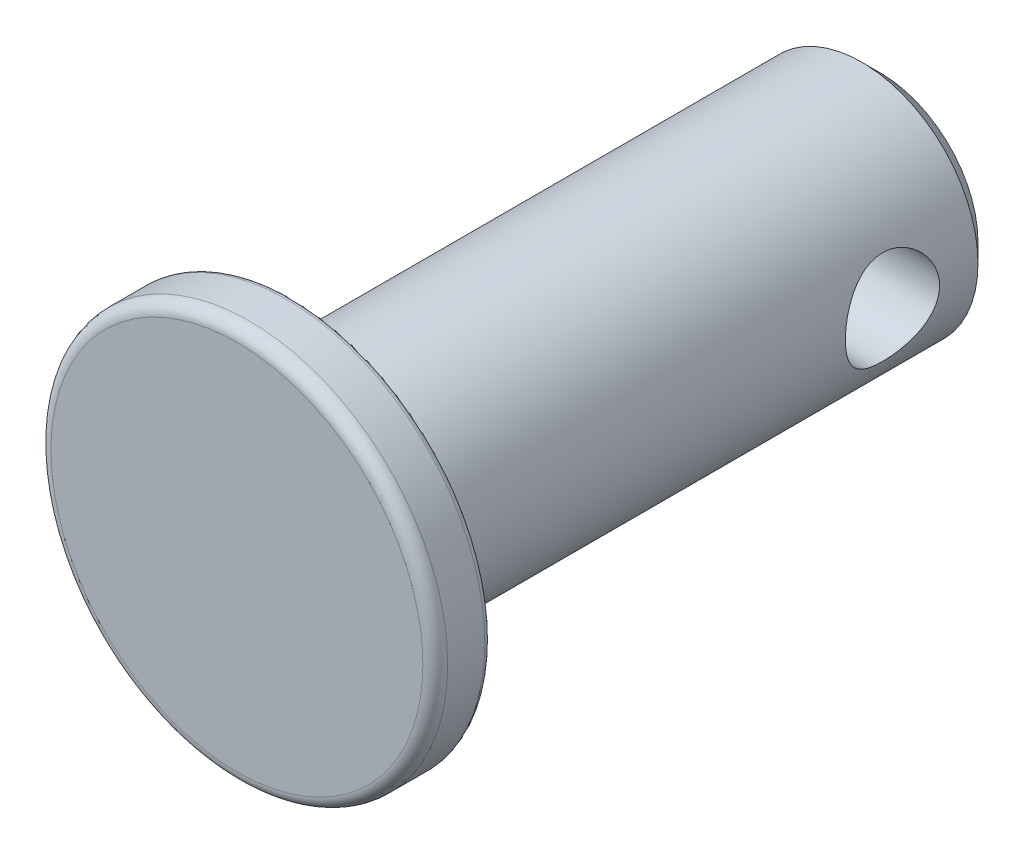
from build123d import *

# Parameters (mm, degrees)
SKETCH2_R           = 0.9652
EXTRUDE1_DEPTH      = 5.0640001
EXTRUDE1_DEPTH_BACK = 5.0640001


with BuildPart() as part:
    # Sketch1 → Revolve Base (revolve)
    with BuildSketch(Plane(origin=(0, 0, 0), x_dir=(0, 0, -1), z_dir=(1, 0, 0))):
        with BuildLine():
            Line((0, 0), (0, 3.81))
            ThreePointArc((0, 3.81), (0.074394878, 3.989605122), (0.254, 4.064))
            Line((0.254, 4.064), (1.016, 4.064))
            ThreePointArc((1.016, 4.064), (1.105802561, 4.026802561), (1.143, 3.937))
            Line((1.143, 3.937), (1.143, 2.38125))
            Line((1.143, 2.38125), (12.8016, 2.38125))
            Line((12.8016, 2.38125), (13.1826, 2.00025))
            Line((13.1826, 2.00025), (13.1826, 0))
            Line((13.1826, 0), (0, 0))
        make_face()
    revolve(axis=Axis((0, 0, 0), (0, 0, -1)))

    # Sketch2 → Extrude1 (cut, two sides)
    with BuildSketch(Plane(origin=(0, 0, 0), x_dir=(0, 0, -1), z_dir=(1, 0, 0))) as extrude1_sk:
        with Locations((11.049, 0)):
            Circle(SKETCH2_R)
    extrude(amount=EXTRUDE1_DEPTH, mode=Mode.SUBTRACT)
    extrude(extrude1_sk.sketch, amount=-EXTRUDE1_DEPTH_BACK, mode=Mode.SUBTRACT)


solid = part.part
